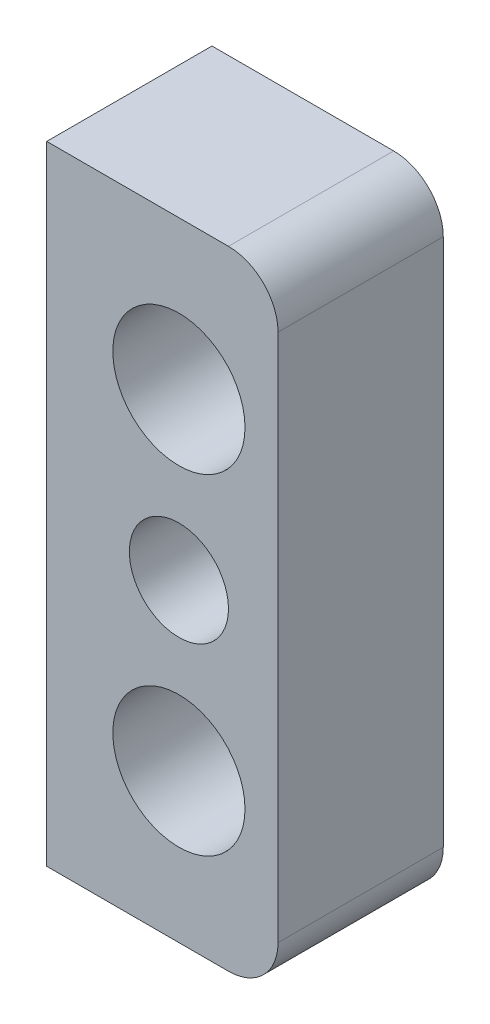
from build123d import *

# Parameters (mm, degrees)
SKETCH1_R           = 2
SKETCH1_R_2         = 1.5
BOSS_EXTRUDE2_DEPTH = 5


with BuildPart() as part:
    # Sketch1 → Boss-Extrude2 (new body)
    with BuildSketch(Plane.XY):
        with BuildLine():
            Line((20, -9.5), (20, 9.5))
            Line((20, 9.5), (25.5, 9.5))
            ThreePointArc((25.5, 9.5), (26.560660172, 9.060660172), (27, 8))
            Line((27, 8), (27, -8))
            ThreePointArc((27, -8), (26.560660172, -9.060660172), (25.5, -9.5))
            Line((25.5, -9.5), (20, -9.5))
        make_face()
        with Locations((24, 5)):
            Circle(SKETCH1_R, mode=Mode.SUBTRACT)
        with Locations((24, -5)):
            Circle(SKETCH1_R, mode=Mode.SUBTRACT)
        with Locations((24, 0)):
            Circle(SKETCH1_R_2, mode=Mode.SUBTRACT)
    extrude(amount=-BOSS_EXTRUDE2_DEPTH)


solid = part.part
